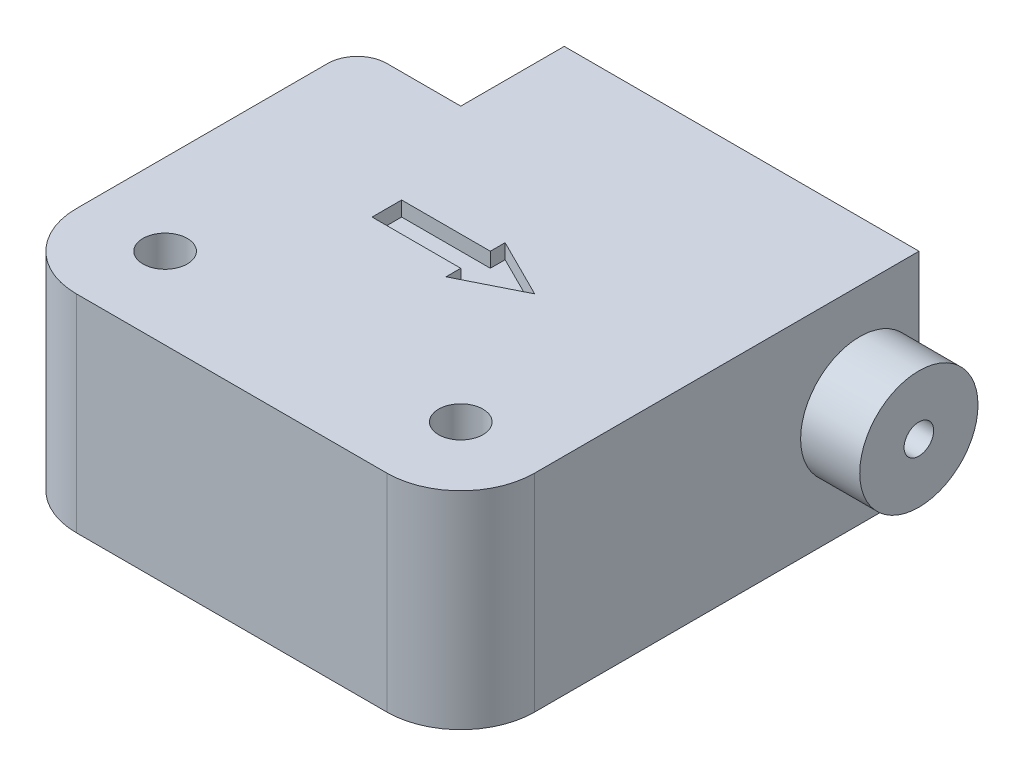
from build123d import *

# Parameters (mm, degrees)
ESBO_O1_R                  = 1.5
RESSALTO_EXTRUS_O1_DEPTH   = 14
FILETE4_R                  = 5
FILETE5_R                  = 2
ESBO_O5_R                  = 4
RESSALTO_EXTRUS_O4_DEPTH   = 4
ESBO_O6_R                  = 1
CORTE_EXTRUS_O3_DEPTH      = 5
CORTE_EXTRUS_O3_DEPTH_BACK = 32
CORTE_EXTRUS_O4_DEPTH      = 1
CORTE_EXTRUS_O5_DEPTH      = 1


with BuildPart() as part:
    # Esboço1 → Ressalto-extrusão1 (new body)
    with BuildSketch(Plane(origin=(0, 0, 0), x_dir=(1, 0, 0), z_dir=(0, 1, 0))):
        Polygon((15.5, 15.5), (-8.5, 15.5), (-8.5, 8.5), (-15.5, 8.5), (-15.5, -15.5), (15.5, -15.5), align=None)
        with Locations((-10, -10)):
            Circle(ESBO_O1_R, mode=Mode.SUBTRACT)
        with Locations((10, -10)):
            Circle(ESBO_O1_R, mode=Mode.SUBTRACT)
    extrude(amount=RESSALTO_EXTRUS_O1_DEPTH)

    # Filete4
    filete4_edges = [part.edges().sort_by_distance(p)[0] for p in [
        (15.5, 7, 15.5),
        (-15.5, 7, 15.5),
    ]]
    fillet(filete4_edges, radius=FILETE4_R)

    # Filete5
    filete5_edges = [part.edges().sort_by_distance(p)[0] for p in [
        (-15.5, 7, -8.5),
    ]]
    fillet(filete5_edges, radius=FILETE5_R)

    # Esboço5 → Ressalto-extrusão4 (add)
    with BuildSketch(Plane(origin=(15.5, 0, 0), x_dir=(0, 0, -1), z_dir=(1, 0, 0))):
        with Locations((11.49, 7)):
            Circle(ESBO_O5_R)
    extrude(amount=RESSALTO_EXTRUS_O4_DEPTH)

    # Esboço6 → Corte-extrusão3 (cut, two sides)
    with BuildSketch(Plane(origin=(15.5, 0, 0), x_dir=(0, 0, -1), z_dir=(1, 0, 0))) as corte_extrus_o3_sk:
        with Locations((11.49, 7)):
            Circle(ESBO_O6_R)
    extrude(amount=CORTE_EXTRUS_O3_DEPTH, mode=Mode.SUBTRACT)
    extrude(corte_extrus_o3_sk.sketch, amount=-CORTE_EXTRUS_O3_DEPTH_BACK, mode=Mode.SUBTRACT)

    # Esboço7 → Corte-extrusão4 (cut)
    with BuildSketch(Plane(origin=(0, 14, 0), x_dir=(1, 0, 0), z_dir=(0, 1, 0))):
        Polygon((-5, 1), (-5, -1), (1, -1), (1, -2), (5, 0), (1, 2), (1, 1), align=None)
    extrude(amount=-CORTE_EXTRUS_O4_DEPTH, mode=Mode.SUBTRACT)

    # Esboço9 → Corte-extrusão5 (cut)
    with BuildSketch(Plane.XZ):
        Polygon((-5.123658733, -0.978330013), (0.876341267, -0.978330013), (0.876341267, -1.978330013), (4.876341267, 0.021669987), (0.876341267, 2.021669987), (0.876341267, 1.021669987), (-5.123658733, 1.021669987), align=None)
    extrude(amount=-CORTE_EXTRUS_O5_DEPTH, mode=Mode.SUBTRACT)


solid = part.part
